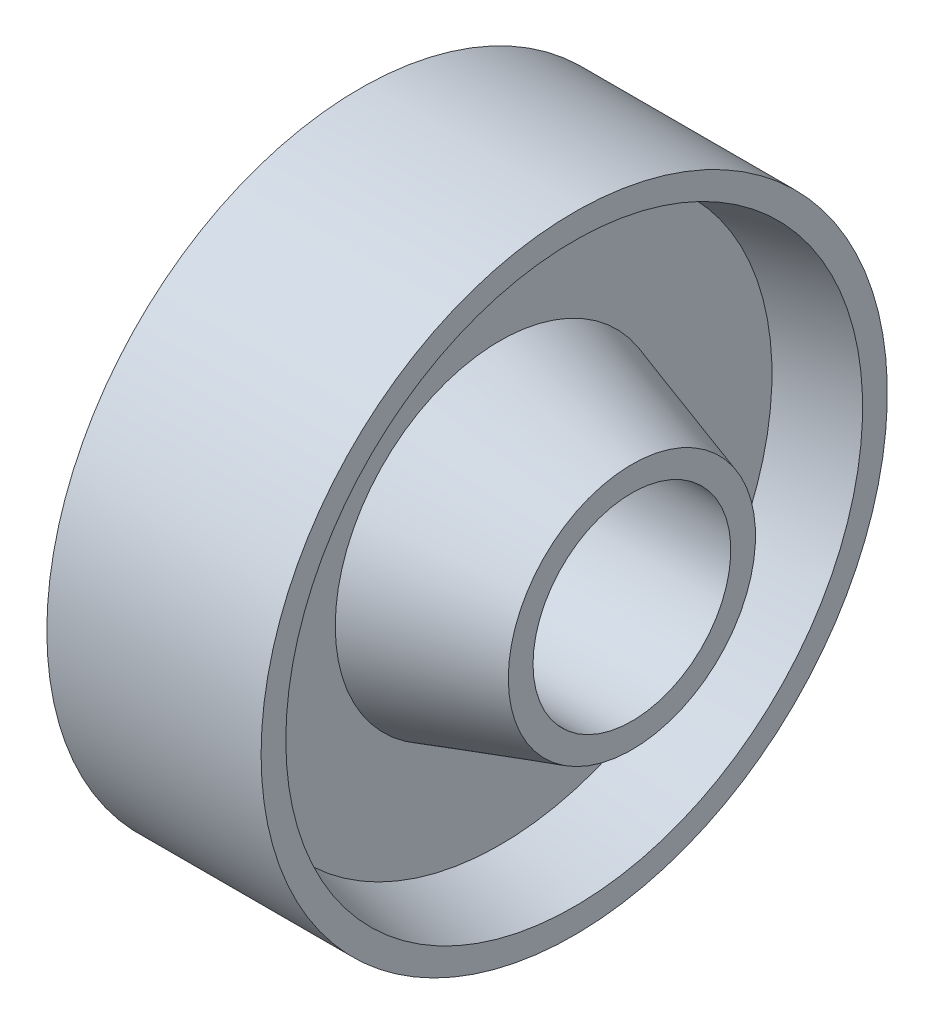
from build123d import *


with BuildPart() as part:
    # Sketch1 → Revolve3 (revolve)
    with BuildSketch(Plane(origin=(0, 0, 0), x_dir=(1, 0, 0), z_dir=(0, 1, 0))):
        Polygon((26.196502876, 12), (66.196502876, 12), (66.196502876, 15), (50.196502876, 20), (50.196502876, 33), (59.196502876, 35), (59.196502876, 38), (33.196502876, 38), (33.196502876, 35), (42.196502876, 33), (42.196502876, 20), (26.196502876, 15), align=None)
    revolve(axis=Axis((0, 0, 0), (1, 0, 0)))


solid = part.part
